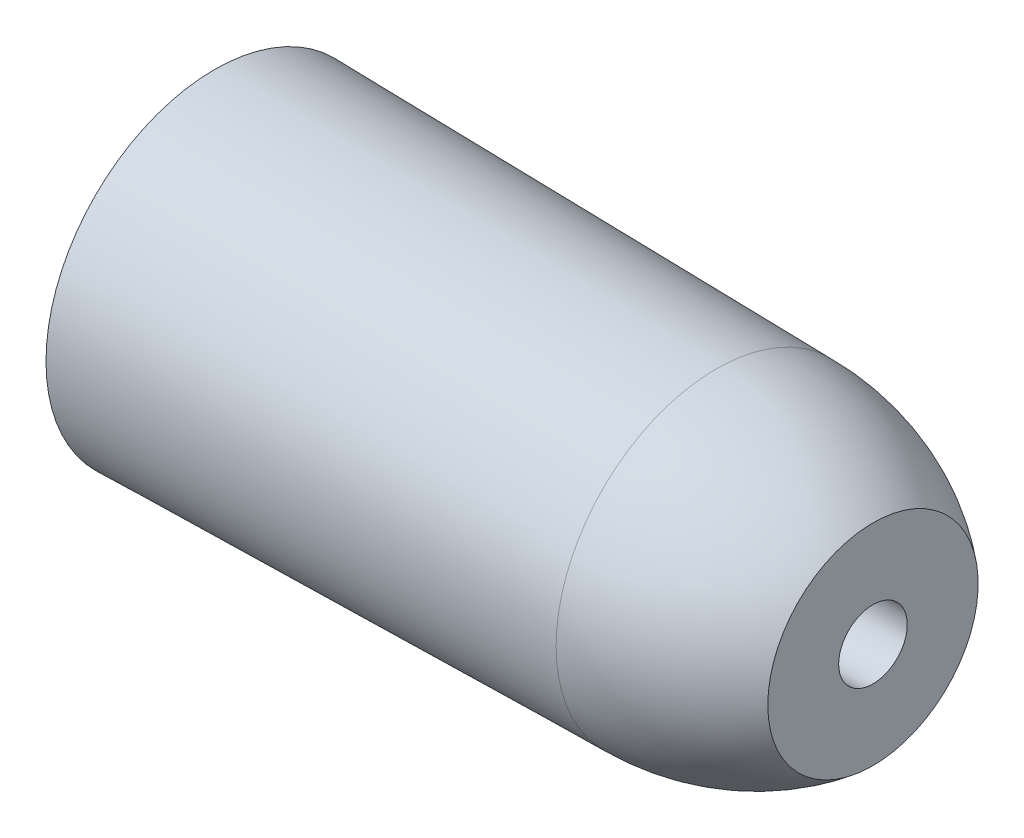
from build123d import *


with BuildPart() as part:
    # Sketch1 one side → Revolve1 (revolve)
    with BuildSketch(Plane(origin=(0, 0, 0), x_dir=(1, 0, 0), z_dir=(0, 1, 0))):
        with BuildLine():
            Line((-82.55, 60.79718825), (-273.05, 63.9802871))
            Line((-273.05, 63.9802871), (-273.05, 12.3))
            Line((-273.05, 12.3), (-23.05, 13.032466581))
            Line((-23.05, 13.032466581), (-23.05, 39.936141717))
            ThreePointArc((-23.05, 39.936141717), (-51.024481517, 55.430809276), (-82.55, 60.79718825))
        make_face()
    revolve(axis=Axis((-491.53912206, 0, 0), (1, 0, 0)))


solid = part.part
